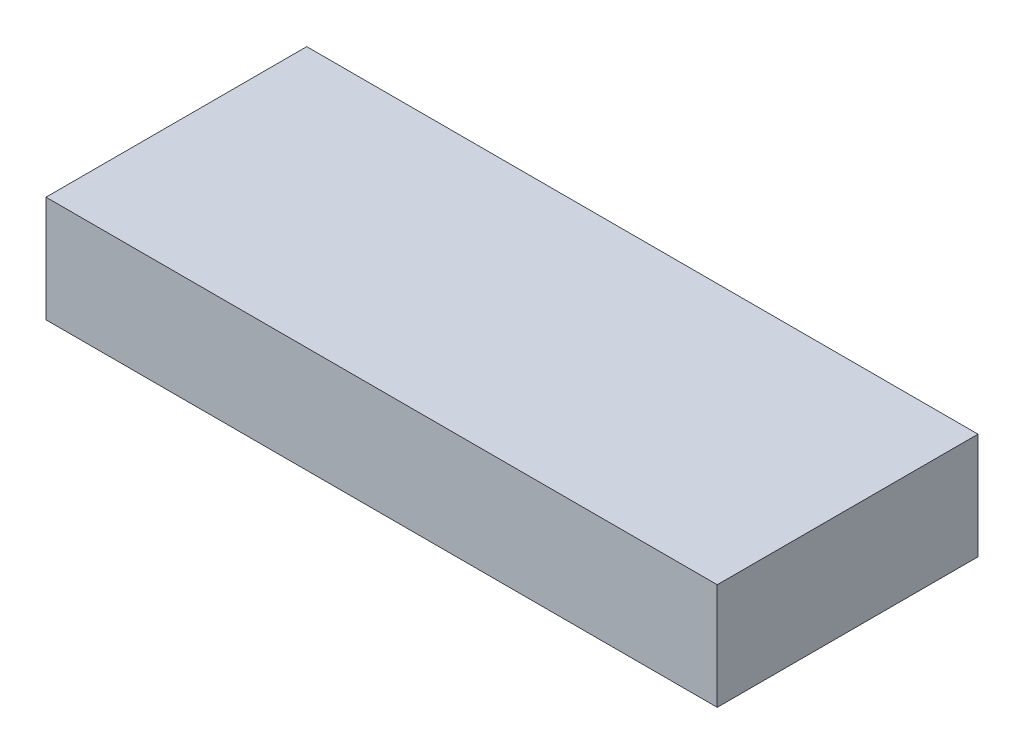
from build123d import *

# Parameters (mm, degrees)
SKETCH1_W           = 126.371227744
SKETCH1_H           = 49.091212658
BOSS_EXTRUDE1_DEPTH = 20


with BuildPart() as part:
    # Sketch1 → Boss-Extrude1 (new body)
    with BuildSketch(Plane(origin=(0, 0, 0), x_dir=(1, 0, 0), z_dir=(0, 1, 0))):
        Rectangle(SKETCH1_W, SKETCH1_H)
    extrude(amount=BOSS_EXTRUDE1_DEPTH)


solid = part.part
